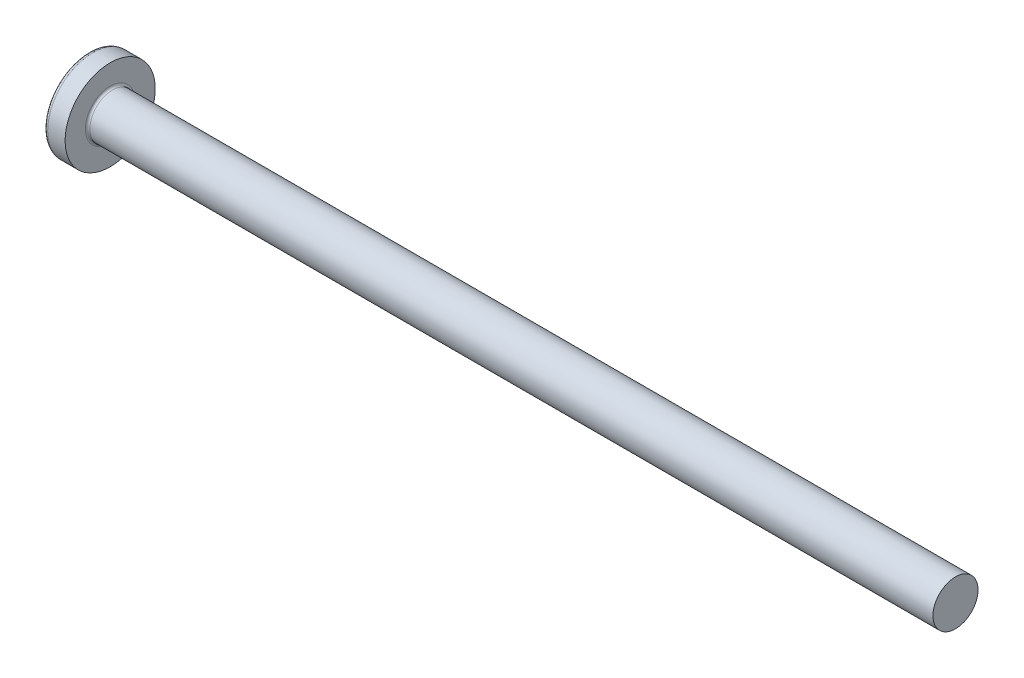
from build123d import *

# Parameters (mm, degrees)
FILLET1_R    = 0.2
SKETCH3_W    = 1.03
SKETCH3_H    = 4.3
SKETCH4_W    = 1.03
SKETCH4_H    = 1.966638464
RECPAT_COUNT = 2
RECPAT_ANGLE = 90


with BuildPart() as part:
    # BodySke → Base-Revolve (revolve)
    with BuildSketch(Plane.XY):
        with BuildLine():
            Line((3.1, 2), (3.1, 4))
            Line((3.1, 4), (1.555305874, 4))
            ThreePointArc((1.555305874, 4), (1.392873227, 3.961271902), (1.265388955, 3.853420195))
            ThreePointArc((1.265388955, 3.853420195), (0.324444487, 2.027933456), (0, 0))
            Line((0, 0), (78.1, 0))
            Line((78.1, 0), (78.1, 2))
            Line((78.1, 2), (3.1, 2))
        make_face()
    revolve(axis=Axis((-25.4, 0, 0), (1, 0, 0)))

    # Fillet1
    fillet1_edges = [part.edges().sort_by_distance(p)[0] for p in [
        (3.1, -2, 0),
    ]]
    fillet(fillet1_edges, radius=FILLET1_R)

    # Sketch3 → Recess section 0
    with BuildSketch(Plane(origin=(0, 0, 0), x_dir=(0, 0, -1), z_dir=(1, 0, 0))):
        Rectangle(SKETCH3_W, SKETCH3_H)
    # Sketch4 → Recess section 1
    with BuildSketch(Plane(origin=(2.34, 0, 0), x_dir=(0, 0, -1), z_dir=(1, 0, 0))):
        Rectangle(SKETCH4_W, SKETCH4_H)
    recess = loft(mode=Mode.SUBTRACT)

    # RecPat: Recess ×2 about axis
    recpat_axis = Axis((0, 0, 0), (1, 0, 0))
    for i in range(1, RECPAT_COUNT):
        add(recess.rotate(recpat_axis, i * RECPAT_ANGLE / (RECPAT_COUNT - 1)), mode=Mode.SUBTRACT)

    # RecCorSke → RecessCore (revolve, cut)
    with BuildSketch(Plane.XY):
        Polygon((0, 0), (0, 1.01462874), (2.34, 0.851), (2.616506661, 0), align=None)
    revolve(axis=Axis((-3.175, 0, 0), (1, 0, 0)), mode=Mode.SUBTRACT)


solid = part.part
